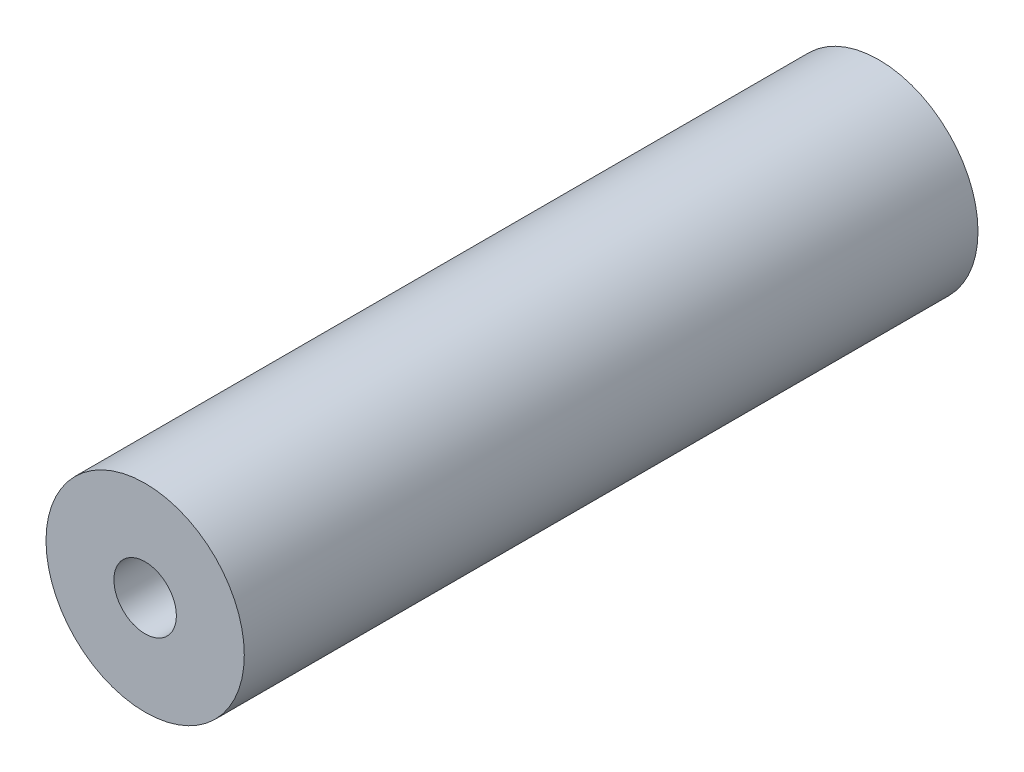
from build123d import *

# Parameters (mm, degrees)
ESBO_O1_R                               = 5
RESSALTO_EXTRUS_O1_DEPTH                = 37
FURO_ROSCADO_PARA_CONDU_TE_DE_M3X0_51_D = 3.15


with BuildPart() as part:
    # Esboço1 → Ressalto-extrusão1 (new body)
    with BuildSketch(Plane.XY):
        Circle(ESBO_O1_R)
    extrude(amount=RESSALTO_EXTRUS_O1_DEPTH)

    # Furo roscado para conduíte de M3x0.51 (through all)
    with Locations(Plane.XY.offset(37)):
        with Locations((0, 0)):
            Hole(FURO_ROSCADO_PARA_CONDU_TE_DE_M3X0_51_D / 2)


solid = part.part
